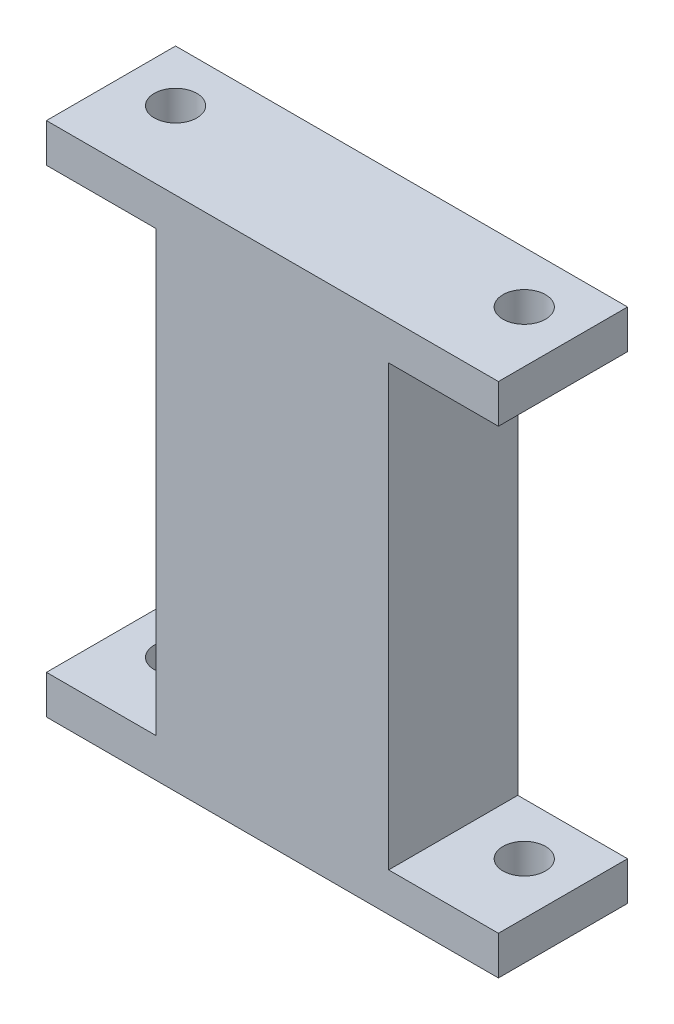
from build123d import *

# Parameters (mm, degrees)
SKETCH1_W           = 35
SKETCH1_H           = 10
BOSS_EXTRUDE1_DEPTH = 1.5
SKETCH2_R           = 1.65
CUT_EXTRUDE1_DEPTH  = 3
SKETCH3_W           = 18
SKETCH3_H           = 10
BOSS_EXTRUDE2_DEPTH = 34


with BuildPart() as part:
    # Sketch1 → Boss-Extrude1 (new body, symmetric)
    with BuildSketch(Plane(origin=(0, 0, 0), x_dir=(1, 0, 0), z_dir=(0, 1, 0))):
        Rectangle(SKETCH1_W, SKETCH1_H)
    boss_extrude1 = extrude(amount=BOSS_EXTRUDE1_DEPTH, both=True)

    # Sketch2 → Cut-Extrude1 (cut)
    with BuildSketch(Plane(origin=(0, 1.5, 0), x_dir=(1, 0, 0), z_dir=(0, 1, 0))):
        with Locations((-13.5, 1)):
            Circle(SKETCH2_R)
        with Locations((13.5, 1)):
            Circle(SKETCH2_R)
    cut_extrude1 = extrude(amount=-CUT_EXTRUDE1_DEPTH, mode=Mode.SUBTRACT)

    # Sketch3 → Boss-Extrude2 (add)
    with BuildSketch(Plane(origin=(0, 1.5, 0), x_dir=(1, 0, 0), z_dir=(0, 1, 0))):
        Rectangle(SKETCH3_W, SKETCH3_H)
    extrude(amount=BOSS_EXTRUDE2_DEPTH)

    # Mirror1: Boss-Extrude1, Cut-Extrude1 across plane
    add(boss_extrude1.mirror(Plane.ZX.offset(18.5)))
    add(cut_extrude1.mirror(Plane.ZX.offset(18.5)), mode=Mode.SUBTRACT)


solid = part.part
